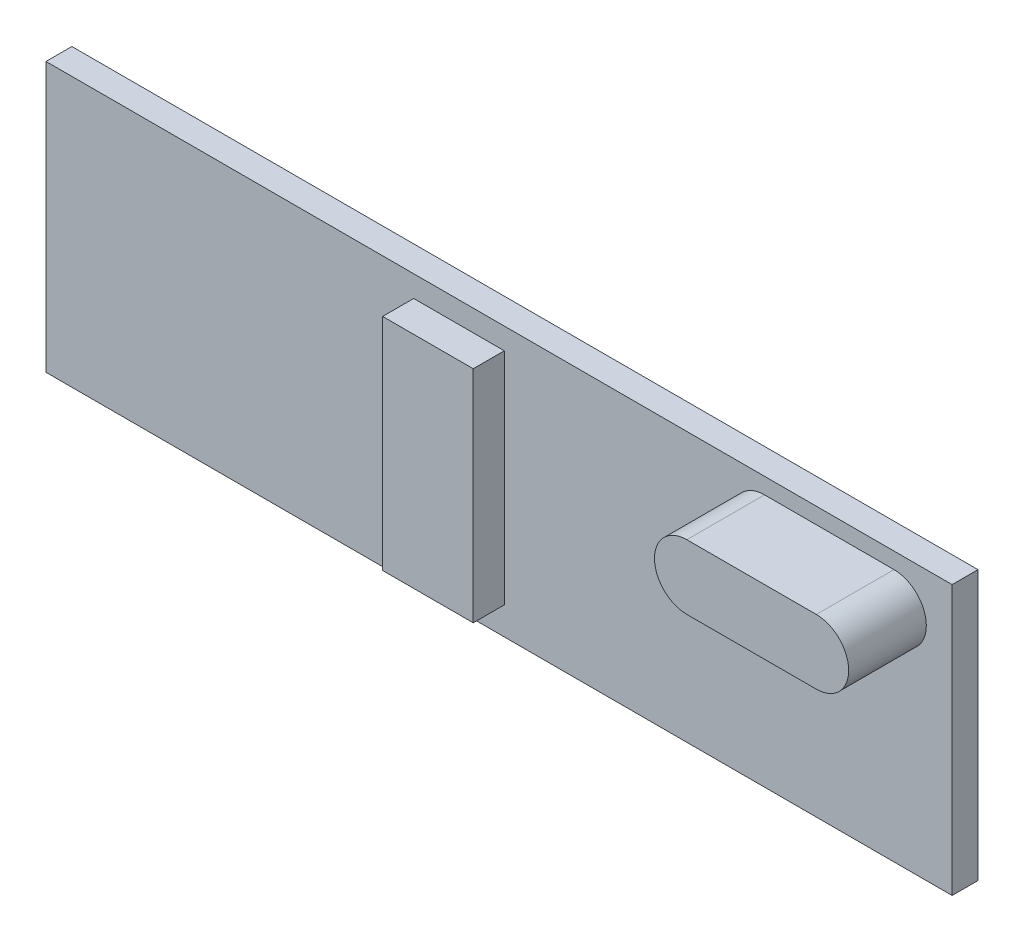
from build123d import *

# Parameters (mm, degrees)
SKETCH1_W           = 35
SKETCH1_H           = 10.4
BOSS_EXTRUDE1_DEPTH = 1
BOSS_EXTRUDE3_DEPTH = 3
SKETCH3_W           = 3.5
SKETCH3_H           = 8.5
BOSS_EXTRUDE4_DEPTH = 1.2


with BuildPart() as part:
    # Sketch1 → Boss-Extrude1 (new body)
    with BuildSketch(Plane.XY):
        Rectangle(SKETCH1_W, SKETCH1_H)
    extrude(amount=BOSS_EXTRUDE1_DEPTH)

    # Sketch2 → Boss-Extrude3 (add)
    with BuildSketch(Plane.XY.offset(1)):
        with BuildLine():
            Line((15.253902663, 2.079032558), (10.253902663, 2.079032558))
            ThreePointArc((10.253902663, 2.079032558), (9.003902663, 3.329032558), (10.253902663, 4.579032558))
            Line((10.253902663, 4.579032558), (15.253902663, 4.579032558))
            ThreePointArc((15.253902663, 4.579032558), (16.503902663, 3.329032558), (15.253902663, 2.079032558))
        make_face()
    extrude(amount=BOSS_EXTRUDE3_DEPTH)

    # Sketch3 → Boss-Extrude4 (add)
    with BuildSketch(Plane.XY.offset(1)):
        with Locations((-1.547221583, 0.122630604)):
            Rectangle(SKETCH3_W, SKETCH3_H)
    extrude(amount=BOSS_EXTRUDE4_DEPTH)


solid = part.part
